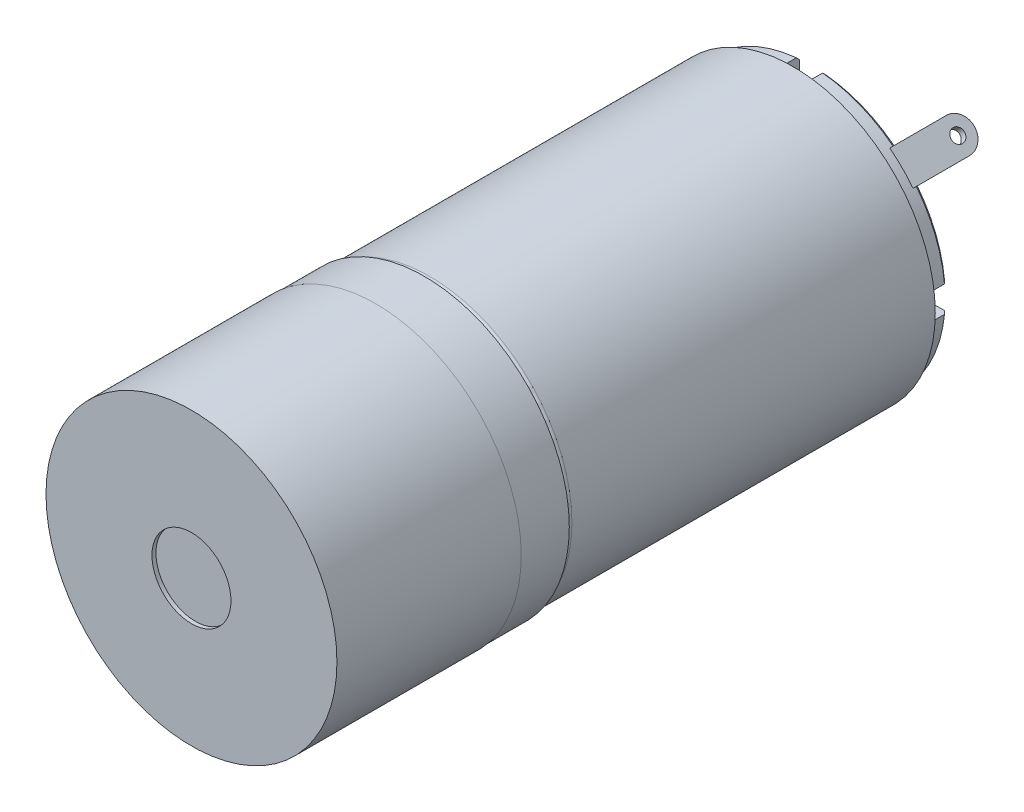
from build123d import *

# Parameters (mm, degrees)
SKETCH1_R           = 11
BOSS_EXTRUDE1_DEPTH = 20.45
SKETCH2_R           = 11
SKETCH2_R_2         = 10.8
CUT_EXTRUDE1_DEPTH  = 30.5
SKETCH5_R           = 0.8
CUT_EXTRUDE2_DEPTH  = 3
BOSS_EXTRUDE2_DEPTH = 2
SKETCH7_R           = 3
BOSS_EXTRUDE3_DEPTH = 12
CUT_EXTRUDE3_DEPTH  = 1
CIRPATTERN1_COUNT   = 4
CIRPATTERN2_COUNT   = 4
SKETCH11_R          = 5
BOSS_EXTRUDE4_DEPTH = 0.25
SKETCH12_R          = 11.05
BOSS_EXTRUDE5_DEPTH = 7
SKETCH14_R          = 1.0375
CUT_EXTRUDE4_DEPTH  = 3
SKETCH16_R          = 10.8
SKETCH16_R_2        = 10.3
CUT_EXTRUDE5_DEPTH  = 1.5
CUT_EXTRUDE6_DEPTH  = 0.5
CUT_EXTRUDE7_DEPTH  = 1.5
CHAMFER1_SIZE       = 0.25
CUT_EXTRUDE8_DEPTH  = 0.5
SKETCH20_R          = 0.5
BOSS_EXTRUDE7_DEPTH = 0.5
CIRPATTERN4_COUNT   = 2
SKETCH22_R          = 3
BOSS_EXTRUDE8_DEPTH = 2
SKETCH23_R          = 1
BOSS_EXTRUDE9_DEPTH = 9.2
CHAMFER2_SIZE       = 0.25
SKETCH24_R          = 1.552462654
CUT_EXTRUDE9_DEPTH  = 10
SKETCH25_R          = 3
CUT_EXTRUDE10_DEPTH = 8


with BuildPart() as part:
    # Sketch1 → Boss-Extrude1 (new body, symmetric)
    with BuildSketch(Plane.XY):
        Circle(SKETCH1_R)
    extrude(amount=BOSS_EXTRUDE1_DEPTH, both=True)

    # Sketch2 → Cut-Extrude1 (cut, through all)
    with BuildSketch(Plane(origin=(0, 0, 9.05), x_dir=(-1, 0, 0), z_dir=(0, 0, -1))):
        Circle(SKETCH2_R)
        Circle(SKETCH2_R_2, mode=Mode.SUBTRACT)
    extrude(amount=CUT_EXTRUDE1_DEPTH, mode=Mode.SUBTRACT)

    # Sketch5 → Cut-Extrude2 (cut)
    with BuildSketch(Plane.XY.offset(20.45)):
        with Locations((-6.363961031, 6.363961031)):
            Circle(SKETCH5_R)
        with Locations((6.363961031, 6.363961031)):
            Circle(SKETCH5_R)
        with Locations((6.363961031, -6.363961031)):
            Circle(SKETCH5_R)
        with Locations((-6.363961031, -6.363961031)):
            Circle(SKETCH5_R)
        with BuildLine():
            Line((-1.5, 9), (-1.5, 10.897247359))
            ThreePointArc((-1.5, 10.897247359), (0, 11), (1.5, 10.897247359))
            Line((1.5, 10.897247359), (1.5, 9))
            ThreePointArc((1.5, 9), (0, 7.5), (-1.5, 9))
        make_face()
        with BuildLine():
            Line((9, 1.5), (10.897247359, 1.5))
            ThreePointArc((10.897247359, 1.5), (11, 0), (10.897247359, -1.5))
            Line((10.897247359, -1.5), (9, -1.5))
            ThreePointArc((9, -1.5), (7.5, 0), (9, 1.5))
        make_face()
        with BuildLine():
            Line((1.5, -9), (1.5, -10.897247359))
            ThreePointArc((1.5, -10.897247359), (0, -11), (-1.5, -10.897247359))
            Line((-1.5, -10.897247359), (-1.5, -9))
            ThreePointArc((-1.5, -9), (0, -7.5), (1.5, -9))
        make_face()
        with BuildLine():
            Line((-9, -1.5), (-10.897247359, -1.5))
            ThreePointArc((-10.897247359, -1.5), (-11, 0), (-10.897247359, 1.5))
            Line((-10.897247359, 1.5), (-9, 1.5))
            ThreePointArc((-9, 1.5), (-7.5, 0), (-9, -1.5))
        make_face()
    extrude(amount=-CUT_EXTRUDE2_DEPTH, mode=Mode.SUBTRACT)

    # Sketch3 → Cut-Revolve3 (revolve, cut)
    with BuildSketch(Plane(origin=(0, 0, 0), x_dir=(0, 0, -1), z_dir=(1, 0, 0))):
        with BuildLine():
            ThreePointArc((-9.05, 10.4), (-8.932842712, 10.682842712), (-8.65, 10.8))
            Line((-8.65, 10.8), (-9.05, 10.8))
            Line((-9.05, 10.8), (-9.05, 10.4))
        make_face()
    revolve(axis=Axis((0, 0, -27.758521673), (0, 0, 1)), mode=Mode.SUBTRACT)

    # Sketch6 → Boss-Extrude2 (add)
    with BuildSketch(Plane.XY.offset(20.45)):
        with BuildLine():
            Line((-6, -3.605551275), (-6, 3.605551275))
            ThreePointArc((-6, 3.605551275), (0, 7), (6, 3.605551275))
            Line((6, 3.605551275), (6, -3.605551275))
            ThreePointArc((6, -3.605551275), (0, -7), (-6, -3.605551275))
        make_face()
    extrude(amount=BOSS_EXTRUDE2_DEPTH)

    # Sketch7 → Boss-Extrude3 (add)
    with BuildSketch(Plane.XY.offset(22.45)):
        Circle(SKETCH7_R)
    extrude(amount=BOSS_EXTRUDE3_DEPTH)

    # Sketch9 → Revolve1 (revolve)
    with BuildSketch(Plane(origin=(0, 9, 0), x_dir=(1, 0, 0), z_dir=(0, 1, 0))):
        with BuildLine():
            Line((0, -17.45), (0, -18.65))
            Line((0, -18.65), (0.85, -18.65))
            ThreePointArc((0.85, -18.65), (1.168198052, -18.518198052), (1.3, -18.2))
            Line((1.3, -18.2), (1.3, -17.45))
            Line((1.3, -17.45), (0, -17.45))
        make_face()
    revolve1 = revolve(axis=Axis((0, 9, 17.45), (0, 0, 1)))

    # Sketch10 → Cut-Extrude3 (cut)
    with BuildSketch(Plane.XY.offset(18.65)):
        with BuildLine():
            Line((0.15, 9.15), (1.291317157, 9.15))
            ThreePointArc((1.291317157, 9.15), (1.3, 9), (1.291317157, 8.85))
            Line((1.291317157, 8.85), (0.15, 8.85))
            Line((0.15, 8.85), (-0.15, 8.85))
            Line((-0.15, 8.85), (-1.291317157, 8.85))
            ThreePointArc((-1.291317157, 8.85), (-1.3, 9), (-1.291317157, 9.15))
            Line((-1.291317157, 9.15), (-0.15, 9.15))
            Line((-0.15, 9.15), (0.15, 9.15))
        make_face()
    cut_extrude3 = extrude(amount=-CUT_EXTRUDE3_DEPTH, mode=Mode.SUBTRACT)

    # CirPattern1: Revolve1 ×4 about axis
    cirpattern1_axis = Axis((0, 0, 0), (0, 0, 1))
    for i in range(1, CIRPATTERN1_COUNT):
        add(revolve1.rotate(cirpattern1_axis, i * 360 / CIRPATTERN1_COUNT))

    # CirPattern2: Cut-Extrude3 ×4 about axis
    cirpattern2_axis = Axis((0, 0, -27.758521673), (0, 0, 1))
    for i in range(1, CIRPATTERN2_COUNT):
        add(cut_extrude3.rotate(cirpattern2_axis, i * 360 / CIRPATTERN2_COUNT), mode=Mode.SUBTRACT)

    # Sketch11 → Boss-Extrude4 (add)
    with BuildSketch(Plane.XY.offset(22.45)):
        Circle(SKETCH11_R)
    extrude(amount=BOSS_EXTRUDE4_DEPTH)

    # Sketch12 → Boss-Extrude5 (add, symmetric)
    with BuildSketch(Plane(origin=(0, 0, 19.75), x_dir=(-1, 0, 0), z_dir=(0, 0, -1))):
        Circle(SKETCH12_R)
    extrude(amount=BOSS_EXTRUDE5_DEPTH, both=True)

    # Sketch14 → Cut-Extrude4 (cut, symmetric)
    with BuildSketch(Plane(origin=(0, 0, 0), x_dir=(0, 0, -1), z_dir=(1, 0, 0))):
        with Locations((-30.35, 0)):
            Circle(SKETCH14_R)
    extrude(amount=CUT_EXTRUDE4_DEPTH, both=True, mode=Mode.SUBTRACT)

    # Sketch16 → Cut-Extrude5 (cut)
    with BuildSketch(Plane(origin=(0, 0, -20.45), x_dir=(-1, 0, 0), z_dir=(0, 0, -1))):
        Circle(SKETCH16_R)
        Circle(SKETCH16_R_2, mode=Mode.SUBTRACT)
    extrude(amount=-CUT_EXTRUDE5_DEPTH, mode=Mode.SUBTRACT)

    # Sketch17 → Cut-Extrude6 (cut)
    with BuildSketch(Plane(origin=(0, 0, -20.45), x_dir=(-1, 0, 0), z_dir=(0, 0, -1))):
        with BuildLine():
            Line((0, 8), (-1, 8))
            Line((-1, 8), (-1, 10.251341376))
            ThreePointArc((-1, 10.251341376), (0, 10.3), (1, 10.251341376))
            Line((1, 10.251341376), (1, 8))
            Line((1, 8), (0, 8))
        make_face()
        with BuildLine():
            Line((8, 1), (10.251341376, 1))
            ThreePointArc((10.251341376, 1), (10.3, 0), (10.251341376, -1))
            Line((10.251341376, -1), (8, -1))
            Line((8, -1), (8, 0))
            Line((8, 0), (8, 1))
        make_face()
        with BuildLine():
            Line((1, -8), (1, -10.251341376))
            ThreePointArc((1, -10.251341376), (0, -10.3), (-1, -10.251341376))
            Line((-1, -10.251341376), (-1, -8))
            Line((-1, -8), (0, -8))
            Line((0, -8), (1, -8))
        make_face()
        with BuildLine():
            Line((-8, -1), (-10.251341376, -1))
            ThreePointArc((-10.251341376, -1), (-10.3, 0), (-10.251341376, 1))
            Line((-10.251341376, 1), (-8, 1))
            Line((-8, 1), (-8, 0))
            Line((-8, 0), (-8, -1))
        make_face()
    extrude(amount=-CUT_EXTRUDE6_DEPTH, mode=Mode.SUBTRACT)

    # Sketch18 → Cut-Extrude7 (cut)
    with BuildSketch(Plane(origin=(0, 0, -20.45), x_dir=(-1, 0, 0), z_dir=(0, 0, -1))):
        with BuildLine():
            Line((-1, 10.251341376), (-1, 9.447221814))
            ThreePointArc((-1, 9.447221814), (0, 9.5), (1, 9.447221814))
            Line((1, 9.447221814), (1, 10.251341376))
            ThreePointArc((1, 10.251341376), (0, 10.3), (-1, 10.251341376))
        make_face()
        with BuildLine():
            Line((10.251341376, 1), (9.447221814, 1))
            ThreePointArc((9.447221814, 1), (9.5, 0), (9.447221814, -1))
            Line((9.447221814, -1), (10.251341376, -1))
            ThreePointArc((10.251341376, -1), (10.3, 0), (10.251341376, 1))
        make_face()
        with BuildLine():
            Line((1, -10.251341376), (1, -9.447221814))
            ThreePointArc((1, -9.447221814), (0, -9.5), (-1, -9.447221814))
            Line((-1, -9.447221814), (-1, -10.251341376))
            ThreePointArc((-1, -10.251341376), (0, -10.3), (1, -10.251341376))
        make_face()
        with BuildLine():
            Line((-10.251341376, -1), (-9.447221814, -1))
            ThreePointArc((-9.447221814, -1), (-9.5, 0), (-9.447221814, 1))
            Line((-9.447221814, 1), (-10.251341376, 1))
            ThreePointArc((-10.251341376, 1), (-10.3, 0), (-10.251341376, -1))
        make_face()
    extrude(amount=-CUT_EXTRUDE7_DEPTH, mode=Mode.SUBTRACT)

    # Chamfer1
    chamfer1_edges = [part.edges().sort_by_distance(p)[0] for p in [
        (-7.283199846, 7.283199846, -20.45),
        (7.283199846, 7.283199846, -20.45),
        (7.283199846, -7.283199846, -20.45),
        (-7.283199846, -7.283199846, -20.45),
    ]]
    chamfer(chamfer1_edges, length=CHAMFER1_SIZE)

    # Sketch19 → Cut-Extrude8 (cut)
    with BuildSketch(Plane(origin=(0, 0, -20.45), x_dir=(-1, 0, 0), z_dir=(0, 0, -1))):
        with BuildLine():
            Line((-6.545347941, 4.777580988), (-8.313114894, 6.545347941))
            ThreePointArc((-8.313114894, 6.545347941), (-7.481626123, 7.481626123), (-6.545347941, 8.313114894))
            Line((-6.545347941, 8.313114894), (-4.777580988, 6.545347941))
            Line((-4.777580988, 6.545347941), (-6.545347941, 4.777580988))
        make_face()
        with BuildLine():
            Line((4.777580988, -6.545347941), (6.545347941, -8.313114894))
            ThreePointArc((6.545347941, -8.313114894), (7.481626123, -7.481626123), (8.313114894, -6.545347941))
            Line((8.313114894, -6.545347941), (6.545347941, -4.777580988))
            Line((6.545347941, -4.777580988), (4.777580988, -6.545347941))
        make_face()
    extrude(amount=-CUT_EXTRUDE8_DEPTH, mode=Mode.SUBTRACT)

    # Sketch20 → Boss-Extrude7 (add)
    with BuildSketch(Plane(origin=(5.661464464, 5.661464464, 0), x_dir=(0, 0, -1), z_dir=(0.707106781, 0.707106781, 0))):
        with BuildLine():
            Line((19.95, 1.25), (25.45, 1.25))
            ThreePointArc((25.45, 1.25), (26.7, 0), (25.45, -1.25))
            Line((25.45, -1.25), (19.95, -1.25))
            Line((19.95, -1.25), (19.95, 1.25))
        make_face()
        with Locations((25.45, 0)):
            Circle(SKETCH20_R, mode=Mode.SUBTRACT)
    boss_extrude7 = extrude(amount=BOSS_EXTRUDE7_DEPTH)

    # CirPattern4: Boss-Extrude7 ×2 about axis
    cirpattern4_axis = Axis((0, 0, 0), (0, 0, 1))
    for i in range(1, CIRPATTERN4_COUNT):
        add(boss_extrude7.rotate(cirpattern4_axis, i * 360 / CIRPATTERN4_COUNT))

    # Sketch22 → Boss-Extrude8 (add)
    with BuildSketch(Plane(origin=(0, 0, -20.45), x_dir=(-1, 0, 0), z_dir=(0, 0, -1))):
        Circle(SKETCH22_R)
    extrude(amount=BOSS_EXTRUDE8_DEPTH)

    # Sketch23 → Boss-Extrude9 (add)
    with BuildSketch(Plane(origin=(0, 0, -22.45), x_dir=(-1, 0, 0), z_dir=(0, 0, -1))):
        Circle(SKETCH23_R)
    extrude(amount=BOSS_EXTRUDE9_DEPTH)

    # Chamfer2
    chamfer2_edges = [part.edges().sort_by_distance(p)[0] for p in [
        (3, 0, -22.45),
    ]]
    chamfer(chamfer2_edges, length=CHAMFER2_SIZE)

    # Sketch24 → Cut-Extrude9 (cut)
    with BuildSketch(Plane(origin=(0, 0, -31.65), x_dir=(-1, 0, 0), z_dir=(0, 0, -1))):
        Circle(SKETCH24_R)
    extrude(amount=-CUT_EXTRUDE9_DEPTH, mode=Mode.SUBTRACT)

    # Sketch25 → Cut-Extrude10 (cut)
    with BuildSketch(Plane.XY.offset(34.45)):
        Circle(SKETCH25_R)
    extrude(amount=-CUT_EXTRUDE10_DEPTH, mode=Mode.SUBTRACT)


solid = part.part
